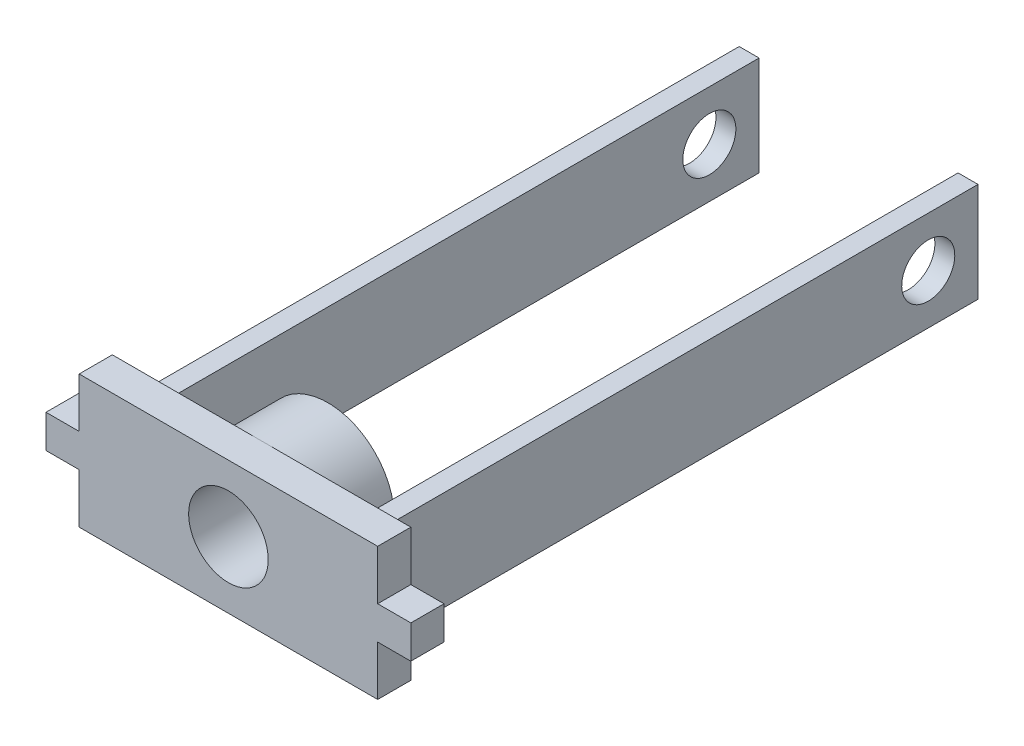
from build123d import *

# Parameters (mm, degrees)
SKETCH_1_R          = 6
EXTRUDE_1_DEPTH     = 5
SKETCH_2_W          = 3
SKETCH_2_H          = 15
EXTRUDE_2_DEPTH     = 90
SKETCH_4_R          = 4
CUT_EXTRUDE_1_DEPTH = 46.5
SKETCH_5_R          = 10
SKETCH_5_R_2        = 6
EXTRUDE_3_DEPTH     = 10


with BuildPart() as part:
    # 草圖1 → 填料-伸長1 (new body)
    with BuildSketch(Plane.XY):
        Polygon((-22.5, -2.5), (-22.5, -10), (22.5, -10), (22.5, -2.5), (27.5, -2.5), (27.5, 2.5), (22.5, 2.5), (22.5, 10), (-22.5, 10), (-22.5, 2.5), (-27.5, 2.5), (-27.5, -2.5), align=None)
        Circle(SKETCH_1_R, mode=Mode.SUBTRACT)
    extrude(amount=EXTRUDE_1_DEPTH)

    # 草圖2 → 填料-伸長2 (add)
    with BuildSketch(Plane(origin=(0, 0, 0), x_dir=(-1, 0, 0), z_dir=(0, 0, -1))):
        with Locations((-16.5, 0)):
            Rectangle(SKETCH_2_W, SKETCH_2_H)
        with Locations((16.5, 0)):
            Rectangle(SKETCH_2_W, SKETCH_2_H)
    extrude(amount=EXTRUDE_2_DEPTH)

    # 草圖4 → 除料-伸長1 (cut, through all)
    with BuildSketch(Plane(origin=(18, 0, 0), x_dir=(0, 0, -1), z_dir=(1, 0, 0))):
        with Locations((82.5, 0)):
            Circle(SKETCH_4_R)
    extrude(amount=-CUT_EXTRUDE_1_DEPTH, mode=Mode.SUBTRACT)

    # 草圖5 → 填料-伸長3 (add)
    with BuildSketch(Plane(origin=(0, 0, 0), x_dir=(-1, 0, 0), z_dir=(0, 0, -1))):
        Circle(SKETCH_5_R)
        Circle(SKETCH_5_R_2, mode=Mode.SUBTRACT)
    extrude(amount=EXTRUDE_3_DEPTH)


solid = part.part
